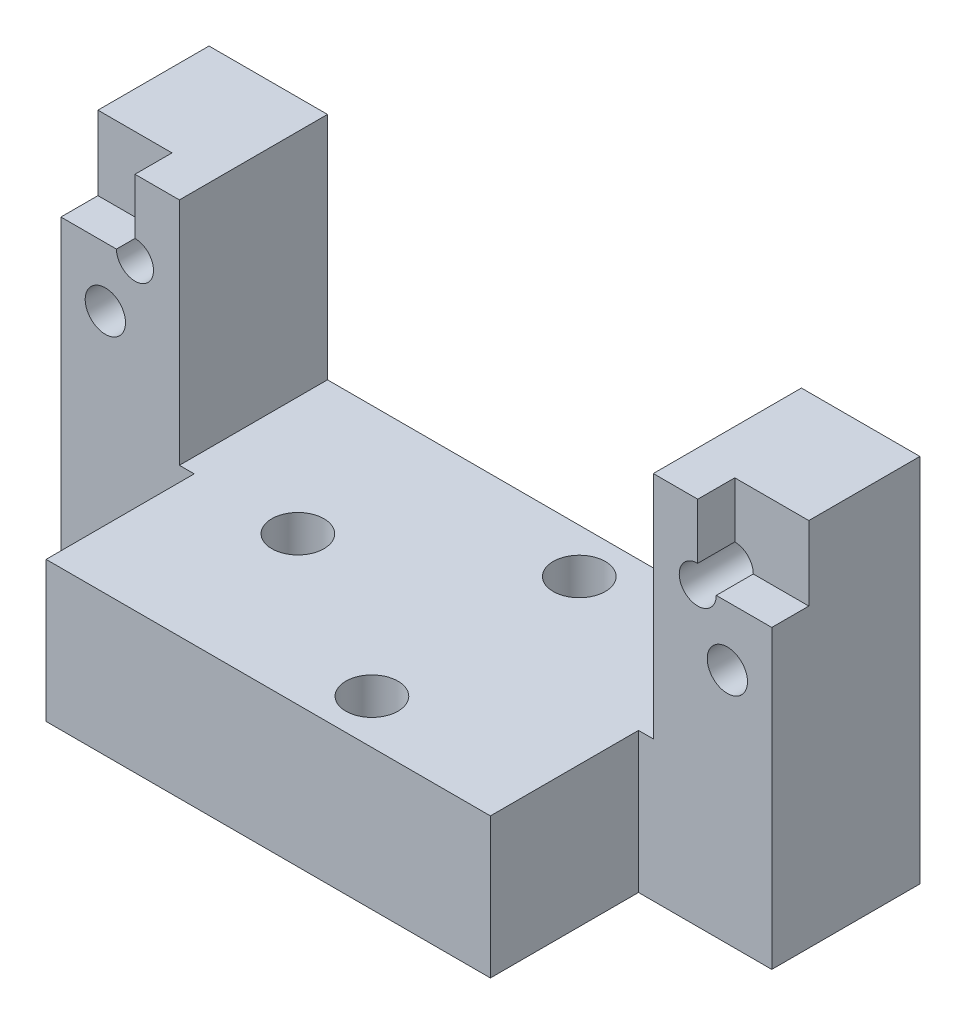
from build123d import *

# Parameters (mm, degrees)
SKETCH1_W                 = 60.96
SKETCH1_H                 = 31.75
BOSS_EXTRUDE1_DEPTH       = 12.7
CUT_EXTRUDE2_REACH        = 27.4
SKETCH4_W                 = 40.64
SKETCH4_H                 = 19.7104
SKETCH5_W                 = 11.43
SKETCH5_H                 = 31.75
CUT_EXTRUDE3_DEPTH        = 12.7
SKETCH6_W                 = 6.35
SKETCH6_H                 = 6.35
CUT_EXTRUDE4_DEPTH        = 3.175
SKETCH7_R                 = 1.5875
CUT_EXTRUDE5_DEPTH        = 6.35
F_8_32_TAPPED_HOLE1_D     = 3.4544
F_8_32_TAPPED_HOLE1_DEPTH = 12.701
CUT_EXTRUDE6_REACH        = 14.04
SKETCH10_R                = 2.2352


with BuildPart() as part:
    # Sketch1 → Boss-Extrude1 (new body, symmetric)
    with BuildSketch(Plane.XY):
        Rectangle(SKETCH1_W, SKETCH1_H)
    extrude(amount=BOSS_EXTRUDE1_DEPTH, both=True)

    # Sketch4 → Cut-Extrude2 (cut, up to next)
    with BuildSketch(Plane.XY.offset(12.7), mode=Mode.PRIVATE) as cut_extrude2_sk1:
        with Locations((0, 6.0198)):
            Rectangle(SKETCH4_W, SKETCH4_H)
    cut_extrude2_tool1 = extrude(cut_extrude2_sk1.sketch, amount=-CUT_EXTRUDE2_REACH, mode=Mode.PRIVATE) & part.part
    add(cut_extrude2_tool1.solids().sort_by_distance((0, 6.0198, 12.7))[0], mode=Mode.SUBTRACT)

    # Sketch5 → Cut-Extrude3 (cut)
    with BuildSketch(Plane.XY.offset(12.7)):
        with Locations((24.765, 0)):
            Rectangle(SKETCH5_W, SKETCH5_H)
    cut_extrude3 = extrude(amount=-CUT_EXTRUDE3_DEPTH, mode=Mode.SUBTRACT)

    # Mirror2: Cut-Extrude3 across plane
    add(cut_extrude3.mirror(Plane(origin=(0, 0, 0), x_dir=(0, 0, 1), z_dir=(1, 0, 0))), mode=Mode.SUBTRACT)

    # Sketch6 → Cut-Extrude4 (cut)
    with BuildSketch(Plane.XY):
        with Locations((27.305, 12.7)):
            Rectangle(SKETCH6_W, SKETCH6_H)
    cut_extrude4 = extrude(amount=-CUT_EXTRUDE4_DEPTH, mode=Mode.SUBTRACT)

    # Sketch7 → Cut-Extrude5 (cut)
    with BuildSketch(Plane.XY):
        with Locations((24.13, 9.525)):
            Circle(SKETCH7_R)
    cut_extrude5 = extrude(amount=-CUT_EXTRUDE5_DEPTH, mode=Mode.SUBTRACT)

    # #8-32 Tapped Hole1
    with Locations(Plane.XY):
        with Locations((26.67, 4.445)):
            f_8_32_tapped_hole1 = Hole(F_8_32_TAPPED_HOLE1_D / 2, depth=F_8_32_TAPPED_HOLE1_DEPTH)

    # Sketch10 → Cut-Extrude6 (cut, up to next)
    with BuildSketch(Plane(origin=(0, -3.8354, 0), x_dir=(1, 0, 0), z_dir=(0, 1, 0)), mode=Mode.PRIVATE) as cut_extrude6_sk1:
        with Locations((5.08, 8.89)):
            Circle(SKETCH10_R)
    cut_extrude6_tool1 = extrude(cut_extrude6_sk1.sketch, amount=-CUT_EXTRUDE6_REACH, mode=Mode.PRIVATE) & part.part
    add(cut_extrude6_tool1.solids().sort_by_distance((5.08, -3.8354, -8.89))[0], mode=Mode.SUBTRACT)
    # Sketch10 → Cut-Extrude6 (cut, up to next)
    with BuildSketch(Plane(origin=(0, -3.8354, 0), x_dir=(1, 0, 0), z_dir=(0, 1, 0)), mode=Mode.PRIVATE) as cut_extrude6_sk2:
        with Locations((5.08, -8.89)):
            Circle(SKETCH10_R)
    cut_extrude6_tool2 = extrude(cut_extrude6_sk2.sketch, amount=-CUT_EXTRUDE6_REACH, mode=Mode.PRIVATE) & part.part
    add(cut_extrude6_tool2.solids().sort_by_distance((5.08, -3.8354, 8.89))[0], mode=Mode.SUBTRACT)
    # Sketch10 → Cut-Extrude6 (cut, up to next)
    with BuildSketch(Plane(origin=(0, -3.8354, 0), x_dir=(1, 0, 0), z_dir=(0, 1, 0)), mode=Mode.PRIVATE) as cut_extrude6_sk3:
        with Locations((-10.16, 0)):
            Circle(SKETCH10_R)
    cut_extrude6_tool3 = extrude(cut_extrude6_sk3.sketch, amount=-CUT_EXTRUDE6_REACH, mode=Mode.PRIVATE) & part.part
    add(cut_extrude6_tool3.solids().sort_by_distance((-10.16, -3.8354, 0))[0], mode=Mode.SUBTRACT)

    # Mirror3: Cut-Extrude4, Cut-Extrude5, #8-32 Tapped Hole1 across plane
    add(cut_extrude4.mirror(Plane(origin=(0, 0, 0), x_dir=(0, 0, 1), z_dir=(1, 0, 0))), mode=Mode.SUBTRACT)
    add(cut_extrude5.mirror(Plane(origin=(0, 0, 0), x_dir=(0, 0, 1), z_dir=(1, 0, 0))), mode=Mode.SUBTRACT)
    add(f_8_32_tapped_hole1.mirror(Plane(origin=(0, 0, 0), x_dir=(0, 0, 1), z_dir=(1, 0, 0))), mode=Mode.SUBTRACT)


solid = part.part
